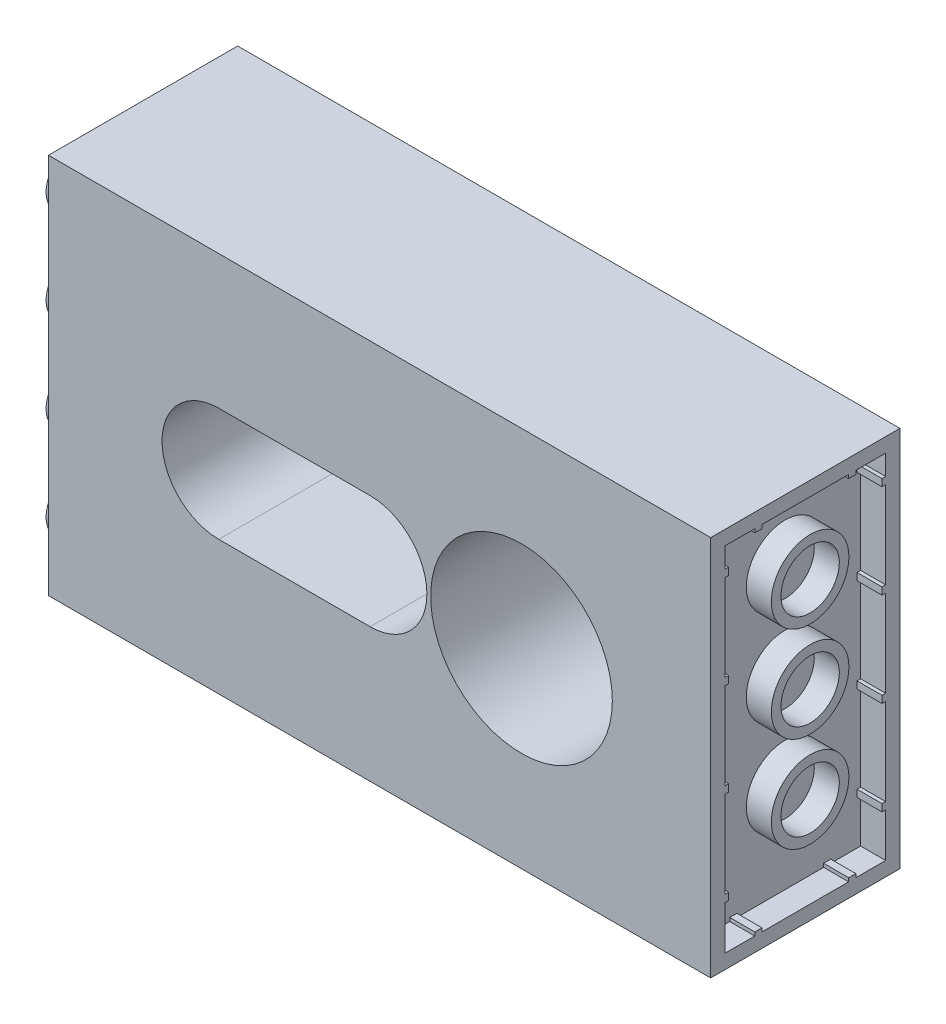
from build123d import *

# Parameters (mm, degrees)
SKETCH1_W               = 55.5625
SKETCH1_H               = 31.75
BOSS_EXTRUDE1_DEPTH     = 28.575
SKETCH2_R               = 7.62
CUT_EXTRUDE1_DEPTH      = 13.335
CUT_EXTRUDE2_DEPTH      = 12.7
SKETCH4_R               = 1.8415
CUT_EXTRUDE3_DEPTH      = 25.4
CUT_EXTRUDE4_START      = -17.78
CUT_EXTRUDE4_DEPTH      = 17.78
SKETCH6_W               = 55.5625
SKETCH6_H               = 28.575
CUT_EXTRUDE5_DEPTH      = 15.875
SKETCH7_R               = 2.778125
CUT_EXTRUDE7_DEPTH      = 7.9375
BOSS_EXTRUDE3_DEPTH     = 4
CUT_EXTRUDE8_DEPTH      = 102.162047202
CUT_EXTRUDE8_DEPTH_BACK = 102.162047202
SKETCH19_R              = 3.255
SKETCH19_R_2            = 2.45
CUT_EXTRUDE11_DEPTH     = 2.1
SKETCH20_R              = 2.4
BOSS_EXTRUDE4_DEPTH     = 1.8


with BuildPart() as part:
    # Sketch1 → Boss-Extrude1 (new body)
    with BuildSketch(Plane(origin=(0, 0, 0), x_dir=(1, 0, 0), z_dir=(0, 1, 0))):
        with Locations((-66.667749699, 35.16562105)):
            Rectangle(SKETCH1_W, SKETCH1_H)
    extrude(amount=BOSS_EXTRUDE1_DEPTH)

    # Sketch2 → Cut-Extrude1 (cut)
    with BuildSketch(Plane.XY.offset(-19.29062105)):
        with Locations((-54.761499699, 16)):
            Circle(SKETCH2_R)
    extrude(amount=-CUT_EXTRUDE1_DEPTH, mode=Mode.SUBTRACT)

    # Sketch3 → Cut-Extrude2 (cut)
    with BuildSketch(Plane.XY.offset(-19.29062105)):
        with BuildLine():
            Line((-80.161499699, 20.7625), (-67.461499699, 20.7625))
            ThreePointArc((-67.461499699, 20.7625), (-62.698999699, 16), (-67.461499699, 11.2375))
            Line((-67.461499699, 11.2375), (-80.161499699, 11.2375))
            ThreePointArc((-80.161499699, 11.2375), (-84.923999699, 16), (-80.161499699, 20.7625))
        make_face()
    extrude(amount=-CUT_EXTRUDE2_DEPTH, mode=Mode.SUBTRACT)

    # Sketch4 → Cut-Extrude3 (cut)
    with BuildSketch(Plane.XY.offset(-31.99062105)):
        with Locations((-80.161499699, 16)):
            Circle(SKETCH4_R)
        with Locations((-67.461499699, 16)):
            Circle(SKETCH4_R)
    extrude(amount=-CUT_EXTRUDE3_DEPTH, mode=Mode.SUBTRACT)

    # Sketch5 → Cut-Extrude4 (cut)
    with BuildSketch(Plane(origin=(0, 0, -51.04062105), x_dir=(-1, 0, 0), z_dir=(0, 0, -1)).offset(CUT_EXTRUDE4_START)):
        with BuildLine():
            Line((67.461499699, 11.2375), (80.161499699, 11.2375))
            ThreePointArc((80.161499699, 11.2375), (84.923999699, 16), (80.161499699, 20.7625))
            Line((80.161499699, 20.7625), (67.461499699, 20.7625))
            ThreePointArc((67.461499699, 20.7625), (62.698999699, 16), (67.461499699, 11.2375))
        make_face()
    extrude(amount=CUT_EXTRUDE4_DEPTH, mode=Mode.SUBTRACT)

    # Sketch6 → Cut-Extrude5 (cut)
    with BuildSketch(Plane(origin=(0, 0, -51.04062105), x_dir=(-1, 0, 0), z_dir=(0, 0, -1))):
        with Locations((66.667749699, 14.2875)):
            Rectangle(SKETCH6_W, SKETCH6_H)
    extrude(amount=-CUT_EXTRUDE5_DEPTH, mode=Mode.SUBTRACT)

    # Sketch7 → Cut-Extrude7 (cut)
    with BuildSketch(Plane.XY.offset(-32.62562105)):
        with Locations((-54.761499699, 16)):
            Circle(SKETCH7_R)
    extrude(amount=-CUT_EXTRUDE7_DEPTH, mode=Mode.SUBTRACT)

    # Sketch10 → Boss-Extrude3 (add)
    with BuildSketch(Plane(origin=(0, 28.575, 0), x_dir=(1, 0, 0), z_dir=(0, 1, 0))):
        Polygon((-38.886499699, 19.29062105), (-38.886499699, 20.962942907), (-38.886499699, 25.368299192), (-38.886499699, 28.962942907), (-38.886499699, 33.368299192), (-38.886499699, 35.16562105), (-94.448999699, 35.16562105), (-94.448999699, 19.29062105), align=None)
    extrude(amount=BOSS_EXTRUDE3_DEPTH)

    # Sketch11 → Cut-Extrude8 (cut, two sides: drawn at the far end of the back side and taken through both)
    with BuildSketch(Plane.XY.offset(-19.29062105).offset(-CUT_EXTRUDE8_DEPTH_BACK)):
        Polygon((-233.263937206, 32), (-94.448999699, 32), (-38.886499699, 32), (-38.886499699, 32.575), (-38.886499699, 0), (-94.448999699, 0), (-94.448999699, 32.575), (-38.886499699, 32.575), (99.928437808, 32.575), (99.449324382, 310.204461605), (-233.743050633, 309.629461605), align=None)
    extrude(amount=CUT_EXTRUDE8_DEPTH + CUT_EXTRUDE8_DEPTH_BACK, mode=Mode.SUBTRACT)


with BuildPart() as cut_extrude8_kept_piece:
    # of the separate pieces the step leaves, the one the design keeps (cut_extrude8_pieces_kept)
    add(part.part.solids().sort_by_distance((-94.448999699, 0, -19.29062105))[0])

    # Sketch19 → Cut-Extrude11 (cut)
    # profile 1 of 4: a face of its own
    with BuildSketch(Plane(origin=(-38.886499699, 0, 0), x_dir=(0, 0, -1), z_dir=(1, 0, 0))):
        Polygon((20.49062105, 30.8), (22.99062105, 30.8), (22.99062105, 30.5), (23.59062105, 30.5), (23.59062105, 30.8), (30.86562105, 30.8), (30.86562105, 30.5), (31.46562105, 30.5), (31.46562105, 30.8), (33.96562105, 30.8), (33.96562105, 29.102775386), (33.66562105, 29.102775386), (33.66562105, 28.502775386), (33.96562105, 28.502775386), (33.96562105, 21.228775386), (33.66562105, 21.228775386), (33.66562105, 20.628775386), (33.96562105, 20.628775386), (33.96562105, 13.354775386), (33.66562105, 13.354775386), (33.66562105, 12.754775386), (33.96562105, 12.754775386), (33.96562105, 5.480775386), (33.66562105, 5.480775386), (33.66562105, 4.880775386), (33.96562105, 4.880775386), (33.96562105, 1.2), (31.46562105, 1.2), (31.46562105, 1.5), (30.86562105, 1.5), (30.86562105, 1.2), (23.59062105, 1.2), (23.59062105, 1.5), (22.99062105, 1.5), (22.99062105, 1.2), (20.49062105, 1.2), (20.49062105, 4.880775386), (20.79062105, 4.880775386), (20.79062105, 5.480775386), (20.49062105, 5.480775386), (20.49062105, 12.754775386), (20.79062105, 12.754775386), (20.79062105, 13.354775386), (20.49062105, 13.354775386), (20.49062105, 20.628775386), (20.79062105, 20.628775386), (20.79062105, 21.228775386), (20.49062105, 21.228775386), (20.49062105, 28.502775386), (20.79062105, 28.502775386), (20.79062105, 29.102775386), (20.49062105, 29.102775386), align=None)
        with Locations((27.631198139, 24.802775386)):
            Circle(SKETCH19_R, mode=Mode.SUBTRACT)
        with Locations((27.631198139, 16.802775386)):
            Circle(SKETCH19_R, mode=Mode.SUBTRACT)
        with Locations((27.631198139, 8.802775386)):
            Circle(SKETCH19_R, mode=Mode.SUBTRACT)
    # profile 2 of 4: a face of its own
    with BuildSketch(Plane(origin=(-38.886499699, 0, 0), x_dir=(0, 0, -1), z_dir=(1, 0, 0))):
        with Locations((27.631198139, 8.802775386)):
            Circle(SKETCH19_R_2)
    # profile 3 of 4: a face of its own
    with BuildSketch(Plane(origin=(-38.886499699, 0, 0), x_dir=(0, 0, -1), z_dir=(1, 0, 0))):
        with Locations((27.631198139, 16.802775386)):
            Circle(SKETCH19_R_2)
    # profile 4 of 4: a face of its own
    with BuildSketch(Plane(origin=(-38.886499699, 0, 0), x_dir=(0, 0, -1), z_dir=(1, 0, 0))):
        with Locations((27.631198139, 24.802775386)):
            Circle(SKETCH19_R_2)
    extrude(amount=-CUT_EXTRUDE11_DEPTH, mode=Mode.SUBTRACT)

    # Sketch20 → Boss-Extrude4 (add)
    with BuildSketch(Plane.ZY.offset(94.448999699)):
        with Locations(Location((-23.29062105, 4, 0), (0, 0, 180))):
            Circle(SKETCH20_R)
        with Locations(Location((-31.29062105, 4, 0), (0, 0, 180))):
            Circle(SKETCH20_R)
        with Locations(Location((-31.29062105, 11.874, 0), (0, 0, 180))):
            Circle(SKETCH20_R)
        with Locations(Location((-23.29062105, 11.874, 0), (0, 0, 180))):
            Circle(SKETCH20_R)
        with Locations(Location((-31.29062105, 19.748, 0), (0, 0, 180))):
            Circle(SKETCH20_R)
        with Locations(Location((-23.29062105, 19.748, 0), (0, 0, 180))):
            Circle(SKETCH20_R)
        with Locations(Location((-31.29062105, 27.622, 0), (0, 0, 180))):
            Circle(SKETCH20_R)
        with Locations(Location((-23.29062105, 27.622, 0), (0, 0, 180))):
            Circle(SKETCH20_R)
    extrude(amount=BOSS_EXTRUDE4_DEPTH)


solid = cut_extrude8_kept_piece.part
